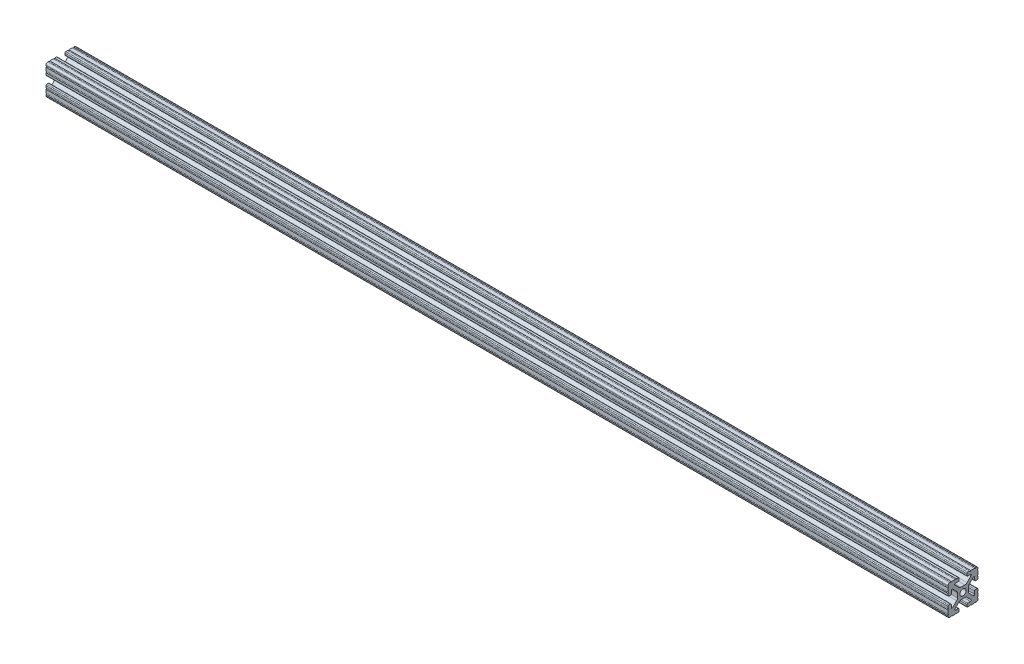
from build123d import *

# Parameters (mm, degrees)
SKETCH2_R           = 2.6035
BOSS_EXTRUDE1_DEPTH = 762


with BuildPart() as part:
    # Sketch2 → Boss-Extrude1 (new body)
    with BuildSketch(Plane(origin=(0, 0, 0), x_dir=(0, 0, -1), z_dir=(1, 0, 0))):
        with BuildLine():
            ThreePointArc((14.334948438, 8.074367167), (15.301384825, 7.882131017), (16.120690033, 7.33468878))
            Line((16.120690033, 7.33468878), (19.543976403, 3.911402409))
            ThreePointArc((19.543976403, 3.911402409), (19.684847869, 3.203193724), (19.084457536, 2.802025729))
            Line((19.084457536, 2.802025729), (16.63615869, 2.802025729))
            ThreePointArc((16.63615869, 2.802025729), (16.142839499, 2.59768623), (15.9385, 2.10436704))
            Line((15.9385, 2.10436704), (15.9385, 0.69765869))
            ThreePointArc((15.9385, 0.69765869), (16.142839499, 0.204339499), (16.63615869, 0))
            Line((16.63615869, 0), (18.269856434, 0))
            ThreePointArc((18.269856434, 0), (18.756204355, 0.361269978), (19.242552277, 0))
            Line((19.242552277, 0), (22.318048746, 0))
            ThreePointArc((22.318048746, 0), (22.808739066, 0.376519925), (23.299429386, 0))
            Line((23.299429386, 0), (24.052572236, 0))
            ThreePointArc((24.052572236, 0), (25.005347545, 0.394652455), (25.4, 1.347427764))
            Line((25.4, 1.347427764), (25.4, 2.100570614))
            ThreePointArc((25.4, 2.100570614), (25.023480075, 2.591260934), (25.4, 3.081951254))
            Line((25.4, 3.081951254), (25.4, 6.157447723))
            ThreePointArc((25.4, 6.157447723), (25.038730022, 6.643795645), (25.4, 7.130143566))
            Line((25.4, 7.130143566), (25.4, 8.76384131))
            ThreePointArc((25.4, 8.76384131), (25.195660501, 9.257160501), (24.70234131, 9.4615))
            Line((24.70234131, 9.4615), (23.29563296, 9.4615))
            ThreePointArc((23.29563296, 9.4615), (22.80231377, 9.257160501), (22.597974271, 8.76384131))
            Line((22.597974271, 8.76384131), (22.597974271, 6.315542464))
            ThreePointArc((22.597974271, 6.315542464), (22.196806276, 5.715152131), (21.488597591, 5.856023597))
            Line((21.488597591, 5.856023597), (18.06531122, 9.279309967))
            ThreePointArc((18.06531122, 9.279309967), (17.517868983, 10.098615175), (17.325632833, 11.065051562))
            Line((17.325632833, 11.065051562), (17.325632833, 14.334948438))
            ThreePointArc((17.325632833, 14.334948438), (17.517868983, 15.301384825), (18.06531122, 16.120690033))
            Line((18.06531122, 16.120690033), (21.488597591, 19.543976403))
            ThreePointArc((21.488597591, 19.543976403), (22.196806276, 19.684847869), (22.597974271, 19.084457536))
            Line((22.597974271, 19.084457536), (22.597974271, 16.63615869))
            ThreePointArc((22.597974271, 16.63615869), (22.80231377, 16.142839499), (23.29563296, 15.9385))
            Line((23.29563296, 15.9385), (24.70234131, 15.9385))
            ThreePointArc((24.70234131, 15.9385), (25.195660501, 16.142839499), (25.4, 16.63615869))
            Line((25.4, 16.63615869), (25.4, 18.269856434))
            ThreePointArc((25.4, 18.269856434), (25.038730022, 18.756204355), (25.4, 19.242552277))
            Line((25.4, 19.242552277), (25.4, 22.318048746))
            ThreePointArc((25.4, 22.318048746), (25.023480075, 22.808739066), (25.4, 23.299429386))
            Line((25.4, 23.299429386), (25.4, 24.052572236))
            ThreePointArc((25.4, 24.052572236), (25.005347545, 25.005347545), (24.052572236, 25.4))
            Line((24.052572236, 25.4), (23.299429386, 25.4))
            ThreePointArc((23.299429386, 25.4), (22.808739066, 25.023480075), (22.318048746, 25.4))
            Line((22.318048746, 25.4), (19.242552277, 25.4))
            ThreePointArc((19.242552277, 25.4), (18.756204355, 25.038730022), (18.269856434, 25.4))
            Line((18.269856434, 25.4), (16.63615869, 25.4))
            ThreePointArc((16.63615869, 25.4), (16.142839499, 25.195660501), (15.9385, 24.70234131))
            Line((15.9385, 24.70234131), (15.9385, 23.29563296))
            ThreePointArc((15.9385, 23.29563296), (16.142839499, 22.80231377), (16.63615869, 22.597974271))
            Line((16.63615869, 22.597974271), (19.084457536, 22.597974271))
            ThreePointArc((19.084457536, 22.597974271), (19.684847869, 22.196806276), (19.543976403, 21.488597591))
            Line((19.543976403, 21.488597591), (16.120690033, 18.06531122))
            ThreePointArc((16.120690033, 18.06531122), (15.301384825, 17.517868983), (14.334948438, 17.325632833))
            Line((14.334948438, 17.325632833), (11.065051562, 17.325632833))
            ThreePointArc((11.065051562, 17.325632833), (10.098615175, 17.517868983), (9.279309967, 18.06531122))
            Line((9.279309967, 18.06531122), (5.856023597, 21.488597591))
            ThreePointArc((5.856023597, 21.488597591), (5.715152131, 22.196806276), (6.315542464, 22.597974271))
            Line((6.315542464, 22.597974271), (8.76384131, 22.597974271))
            ThreePointArc((8.76384131, 22.597974271), (9.257160501, 22.80231377), (9.4615, 23.29563296))
            Line((9.4615, 23.29563296), (9.4615, 24.70234131))
            ThreePointArc((9.4615, 24.70234131), (9.257160501, 25.195660501), (8.76384131, 25.4))
            Line((8.76384131, 25.4), (7.130143566, 25.4))
            ThreePointArc((7.130143566, 25.4), (6.643795645, 25.038730022), (6.157447723, 25.4))
            Line((6.157447723, 25.4), (3.081951254, 25.4))
            ThreePointArc((3.081951254, 25.4), (2.591260934, 25.023480075), (2.100570614, 25.4))
            Line((2.100570614, 25.4), (1.347427764, 25.4))
            ThreePointArc((1.347427764, 25.4), (0.394652455, 25.005347545), (0, 24.052572236))
            Line((0, 24.052572236), (0, 23.299429386))
            ThreePointArc((0, 23.299429386), (0.376519925, 22.808739066), (0, 22.318048746))
            Line((0, 22.318048746), (0, 19.242552277))
            ThreePointArc((0, 19.242552277), (0.361269978, 18.756204355), (0, 18.269856434))
            Line((0, 18.269856434), (0, 16.63615869))
            ThreePointArc((0, 16.63615869), (0.204339499, 16.142839499), (0.69765869, 15.9385))
            Line((0.69765869, 15.9385), (2.10436704, 15.9385))
            ThreePointArc((2.10436704, 15.9385), (2.59768623, 16.142839499), (2.802025729, 16.63615869))
            Line((2.802025729, 16.63615869), (2.802025729, 19.084457536))
            ThreePointArc((2.802025729, 19.084457536), (3.203193724, 19.684847869), (3.911402409, 19.543976403))
            Line((3.911402409, 19.543976403), (7.33468878, 16.120690033))
            ThreePointArc((7.33468878, 16.120690033), (7.882131017, 15.301384825), (8.074367167, 14.334948438))
            Line((8.074367167, 14.334948438), (8.074367167, 11.065051562))
            ThreePointArc((8.074367167, 11.065051562), (7.882131017, 10.098615175), (7.33468878, 9.279309967))
            Line((7.33468878, 9.279309967), (3.911402409, 5.856023597))
            ThreePointArc((3.911402409, 5.856023597), (3.203193724, 5.715152131), (2.802025729, 6.315542464))
            Line((2.802025729, 6.315542464), (2.802025729, 8.76384131))
            ThreePointArc((2.802025729, 8.76384131), (2.59768623, 9.257160501), (2.10436704, 9.4615))
            Line((2.10436704, 9.4615), (0.69765869, 9.4615))
            ThreePointArc((0.69765869, 9.4615), (0.204339499, 9.257160501), (0, 8.76384131))
            Line((0, 8.76384131), (0, 7.130143566))
            ThreePointArc((0, 7.130143566), (0.361269978, 6.643795645), (0, 6.157447723))
            Line((0, 6.157447723), (0, 3.081951254))
            ThreePointArc((0, 3.081951254), (0.376519925, 2.591260934), (0, 2.100570614))
            Line((0, 2.100570614), (0, 1.347427764))
            ThreePointArc((0, 1.347427764), (0.394652455, 0.394652455), (1.347427764, 0))
            Line((1.347427764, 0), (2.100570614, 0))
            ThreePointArc((2.100570614, 0), (2.591260934, 0.376519925), (3.081951254, 0))
            Line((3.081951254, 0), (6.157447723, 0))
            ThreePointArc((6.157447723, 0), (6.643795645, 0.361269978), (7.130143566, 0))
            Line((7.130143566, 0), (8.76384131, 0))
            ThreePointArc((8.76384131, 0), (9.257160501, 0.204339499), (9.4615, 0.69765869))
            Line((9.4615, 0.69765869), (9.4615, 2.10436704))
            ThreePointArc((9.4615, 2.10436704), (9.257160501, 2.59768623), (8.76384131, 2.802025729))
            Line((8.76384131, 2.802025729), (6.315542464, 2.802025729))
            ThreePointArc((6.315542464, 2.802025729), (5.715152131, 3.203193724), (5.856023597, 3.911402409))
            Line((5.856023597, 3.911402409), (9.279309967, 7.33468878))
            ThreePointArc((9.279309967, 7.33468878), (10.098615175, 7.882131017), (11.065051562, 8.074367167))
            Line((11.065051562, 8.074367167), (14.334948438, 8.074367167))
        make_face()
        with Locations((12.7, 12.7)):
            Circle(SKETCH2_R, mode=Mode.SUBTRACT)
    extrude(amount=BOSS_EXTRUDE1_DEPTH)


with BuildPart() as part_1:
    # Body-Move/Copy1: moved
    add(part.part.moved(Location((-150.058747395, 28.75970044, 59.645039801))))


solid = part_1.part
